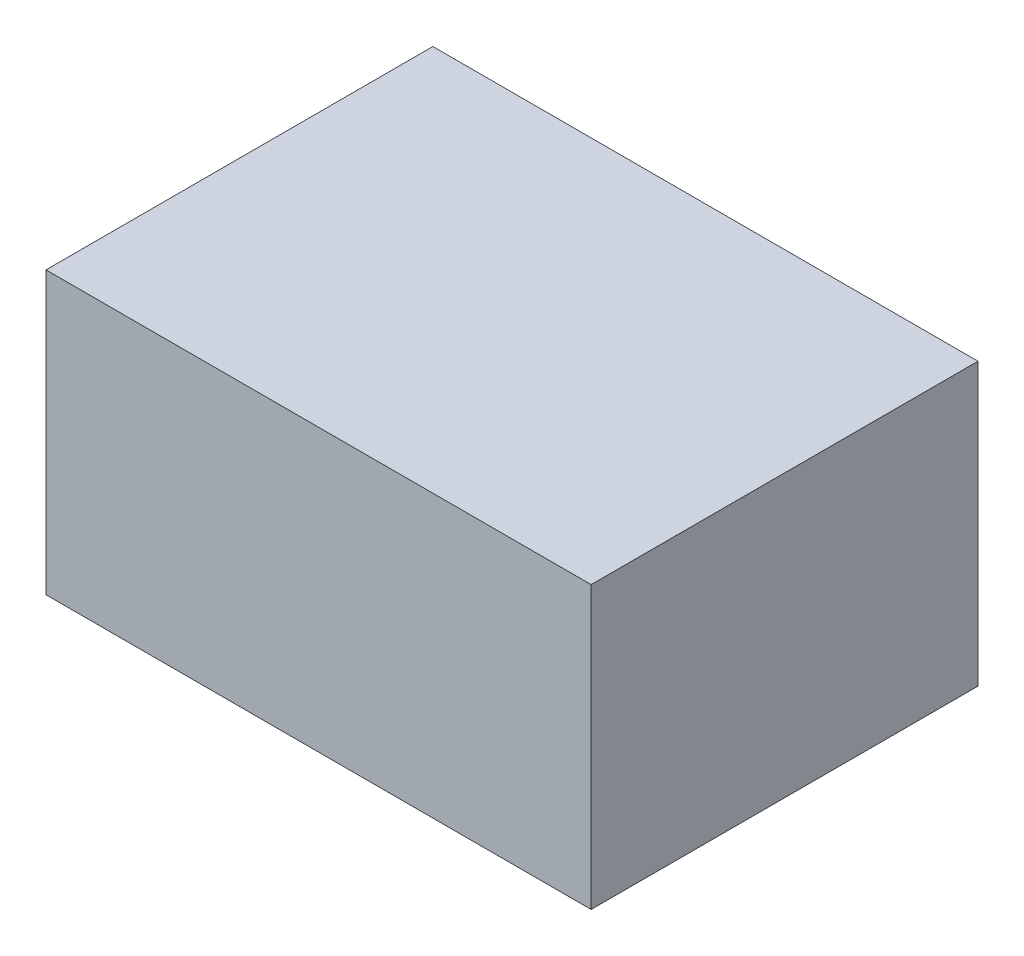
from build123d import *

# Parameters (mm, degrees)
SKETCH1_W           = 62
SKETCH1_H           = 44
BOSS_EXTRUDE1_DEPTH = 32


with BuildPart() as part:
    # Sketch1 → Boss-Extrude1 (new body)
    with BuildSketch(Plane(origin=(0, 0, 0), x_dir=(1, 0, 0), z_dir=(0, 1, 0))):
        with Locations((-28.05647183, -6.564792641)):
            Rectangle(SKETCH1_W, SKETCH1_H)
    extrude(amount=BOSS_EXTRUDE1_DEPTH)


solid = part.part
